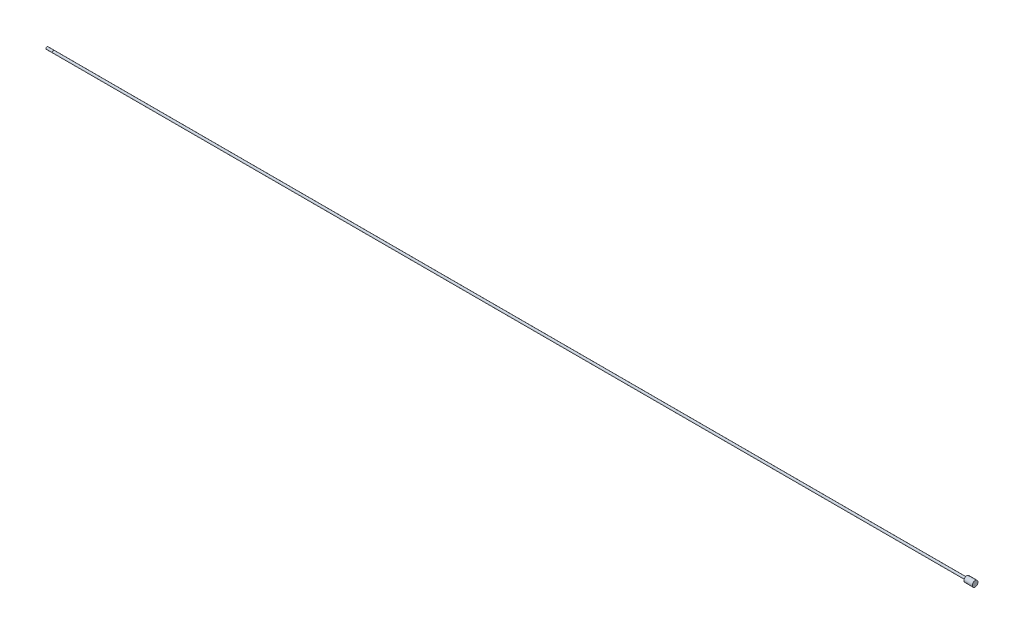
from build123d import *

# Parameters (mm, degrees)
SKETCH3_W = 0.254
SKETCH3_H = 0.508


with BuildPart() as part:
    # Sketch1 → Revolve1 (revolve)
    with BuildSketch(Plane.XY):
        Polygon((0, 0), (0, 1.5875), (1291.463, 1.5875), (1291.463, 4.03225), (1303.2994, 4.03225), (1303.2994, 0), align=None)
    revolve(axis=Axis((1303.2994, 0, 0), (-1, 0, 0)))

    # Sketch2 → Revolve2 (revolve)
    with BuildSketch(Plane.XY):
        Polygon((-9.652, 0), (-9.652, 1.20904), (-9.27354, 1.5875), (0, 1.5875), (0, 0), align=None)
    revolve(axis=Axis((0, 0, 0), (-1, 0, 0)))

    # Sketch3 → Cut-Revolve1 (revolve, cut)
    with BuildSketch(Plane.XY):
        with Locations((-0.127, 1.5875)):
            Rectangle(SKETCH3_W, SKETCH3_H)
    revolve(axis=Axis((0, 0, 0), (-1, 0, 0)), mode=Mode.SUBTRACT)


solid = part.part
